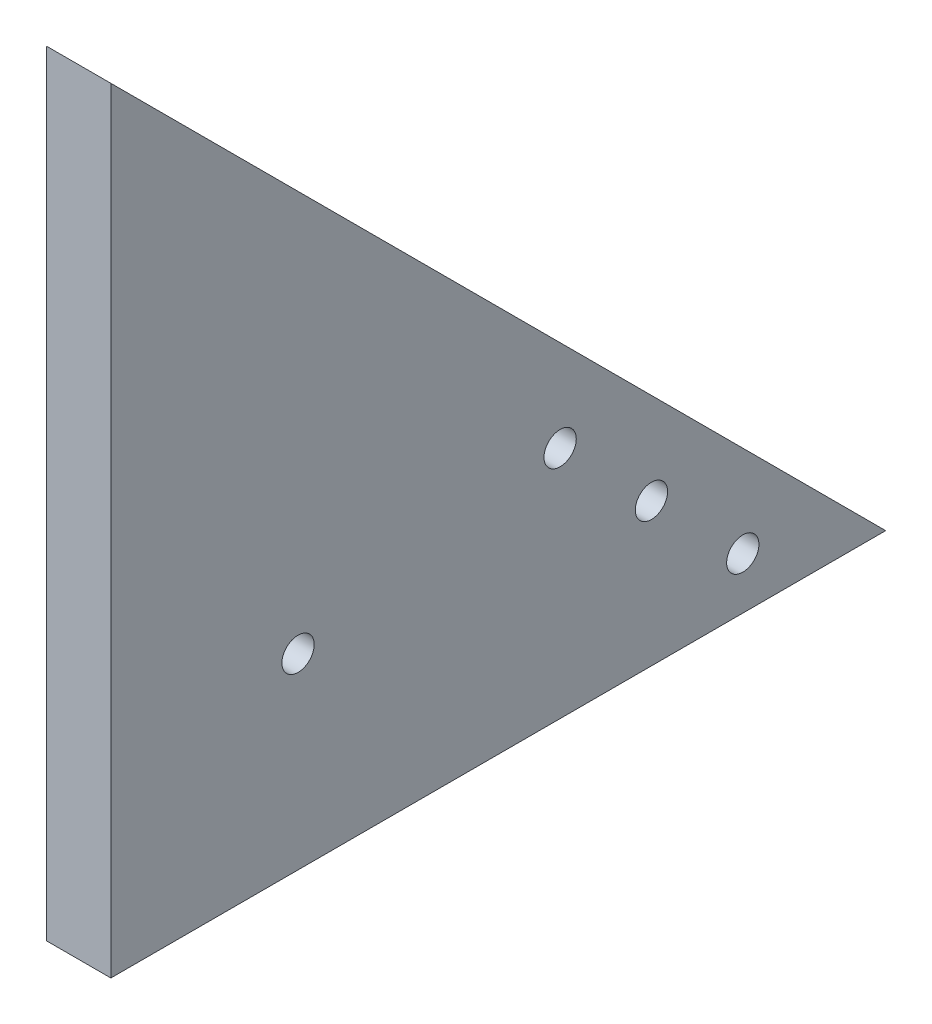
from build123d import *

# Parameters (mm, degrees)
BOSS_EXTRUDE1_DEPTH = 10
SKETCH4_R           = 2.5
CUT_EXTRUDE3_DEPTH  = 10


with BuildPart() as part:
    # Sketch1 → Boss-Extrude1 (new body)
    with BuildSketch(Plane(origin=(0, 0, 0), x_dir=(0, 0, -1), z_dir=(1, 0, 0))):
        Polygon((0, 0), (0, 120), (120, 0), align=None)
    extrude(amount=BOSS_EXTRUDE1_DEPTH)

    # Sketch4 → Cut-Extrude3 (cut)
    with BuildSketch(Plane(origin=(10, 0, 0), x_dir=(0, 0, -1), z_dir=(1, 0, 0))):
        with Locations((83.720628574, 22.137235802)):
            Circle(SKETCH4_R)
        with Locations((97.862764198, 7.995100178)):
            Circle(SKETCH4_R)
        with Locations((69.578492951, 36.279371426)):
            Circle(SKETCH4_R)
        with Locations((28.991378029, 28.991378029)):
            Circle(SKETCH4_R)
    extrude(amount=-CUT_EXTRUDE3_DEPTH, mode=Mode.SUBTRACT)


solid = part.part
